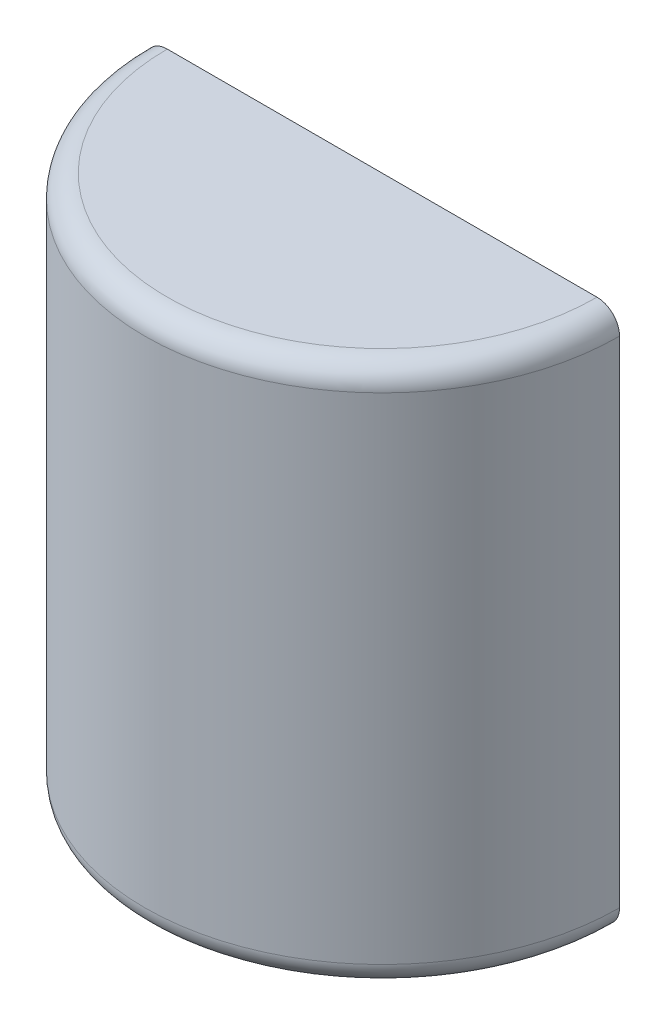
from build123d import *

# Parameters (mm, degrees)
SKETCH1_W      = 133.985
SKETCH1_H      = 304.8
REVOLVE1_ANGLE = 180
FILLET1_R      = 12.7


with BuildPart() as part:
    # Sketch1 → Revolve1 (revolve)
    with BuildSketch(Plane.XY):
        with Locations((-66.9925, 152.4)):
            Rectangle(SKETCH1_W, SKETCH1_H)
    revolve(axis=Axis((0, 0, 0), (0, 1, 0)), revolution_arc=REVOLVE1_ANGLE)

    # Fillet1
    fillet1_edges = [part.edges().sort_by_distance(p)[0] for p in [
        (0, 0, 133.985),
        (0, 304.8, 133.985),
    ]]
    fillet(fillet1_edges, radius=FILLET1_R)


solid = part.part
